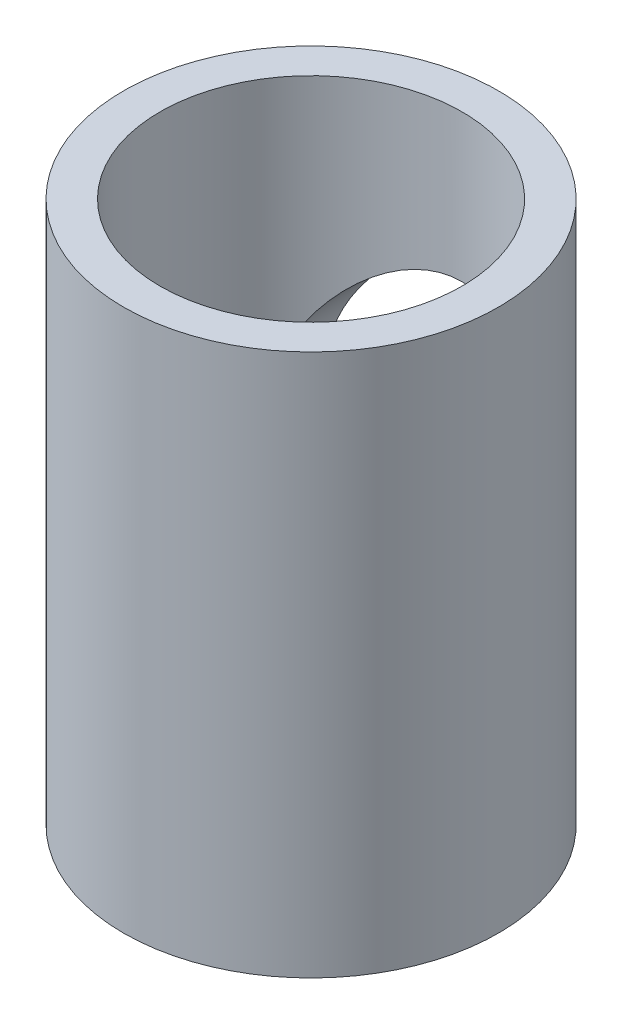
from build123d import *

# Parameters (mm, degrees)
SKETCH1_R           = 3.0734
SKETCH1_R_2         = 2.4765
BOSS_EXTRUDE1_DEPTH = 8.89
SKETCH2_R           = 2.032
CUT_EXTRUDE1_DEPTH  = 8.89


with BuildPart() as part:
    # Sketch1 → Boss-Extrude1 (new body)
    with BuildSketch(Plane(origin=(0, 0, 0), x_dir=(1, 0, 0), z_dir=(0, 1, 0))):
        Circle(SKETCH1_R)
        Circle(SKETCH1_R_2, mode=Mode.SUBTRACT)
    extrude(amount=BOSS_EXTRUDE1_DEPTH)

    # Sketch2 → Cut-Extrude1 (cut)
    with BuildSketch(Plane.XY):
        with Locations((0, 4.445)):
            Circle(SKETCH2_R)
    extrude(amount=-CUT_EXTRUDE1_DEPTH, mode=Mode.SUBTRACT)


solid = part.part
